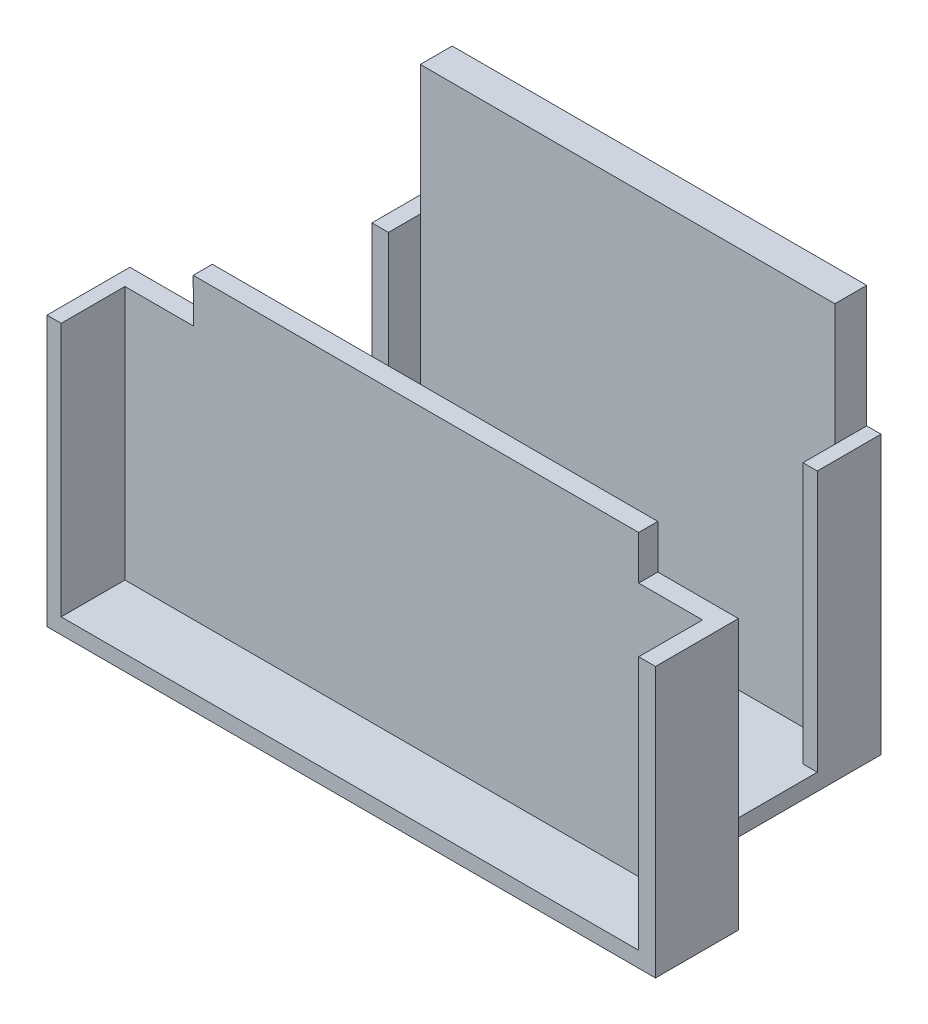
from build123d import *

# Parameters (mm, degrees)
SKETCH_1_W      = 65
SKETCH_1_H      = 60
EXTRUDE_2_DEPTH = 5
SKETCH_2_W      = 2.242579202
SKETCH_2_H      = 40.913257232
EXTRUDE_3_DEPTH = 10
EXTRUDE_4_DEPTH = 10
SKETCH_4_W      = 69.848233062
SKETCH_4_H      = 2.620198038
EXTRUDE_6_DEPTH = 35
EXTRUDE_7_DEPTH = 3
EXTRUDE_9_DEPTH = 10


with BuildPart() as part:
    # 草图1 → 凸台-拉伸2 (new body)
    with BuildSketch(Plane.XY):
        with Locations((13.426561916, 13.374518887)):
            Rectangle(SKETCH_1_W, SKETCH_1_H)
    extrude(amount=EXTRUDE_2_DEPTH)

    # 草图2 → 凸台-拉伸3 (add)
    with BuildSketch(Plane(origin=(0, 0, 0), x_dir=(-1, 0, 0), z_dir=(0, 0, -1))):
        with Locations((-47.047851517, 3.831147503)):
            Rectangle(SKETCH_2_W, SKETCH_2_H)
    extrude(amount=-EXTRUDE_3_DEPTH)

    # 草图3 → 凸台-拉伸4 (add)
    with BuildSketch(Plane(origin=(0, 0, 0), x_dir=(-1, 0, 0), z_dir=(0, 0, -1))):
        Polygon((19.073438084, 23.061567441), (21.666178099, 23.061567441), (21.666178099, -16.667593717), (19.073438084, -16.625481113), align=None)
    extrude(amount=-EXTRUDE_4_DEPTH)

    # 草图4 → 凸台-拉伸6 (add)
    with BuildSketch(Plane(origin=(0, 0, 0), x_dir=(-1, 0, 0), z_dir=(0, 0, -1))):
        with Locations((-13.245024587, -17.935580132)):
            Rectangle(SKETCH_4_W, SKETCH_4_H)
    extrude(amount=-EXTRUDE_6_DEPTH)

    # 草图5 → 凸台-拉伸7 (add)
    with BuildSketch(Plane.XY.offset(35)):
        Polygon((-21.666178099, 23.061567441), (-34.613761508, 23.061567441), (-34.613761508, -19.245679151), (-21.679091944, -19.245679151), (48.169141118, -19.245679151), (60.804068806, -19.245679151), (60.804068806, 23.061567441), (48.169141118, 23.061567441), (48.169141118, 29.937605797), (-21.679091944, 29.937605797), align=None)
    extrude(amount=EXTRUDE_7_DEPTH)

    # 草图7 → 凸台-拉伸9 (add)
    with BuildSketch(Plane.XY.offset(38)):
        Polygon((-32.387714445, 23.061567441), (-34.613761508, 23.061567441), (-34.613761508, -19.245679151), (60.804068806, -19.245679151), (60.804068806, 23.061567441), (58.173614472, 23.061567441), (58.173614472, -16.803323091), (-32.387714445, -16.803323091), align=None)
    extrude(amount=EXTRUDE_9_DEPTH)


solid = part.part
